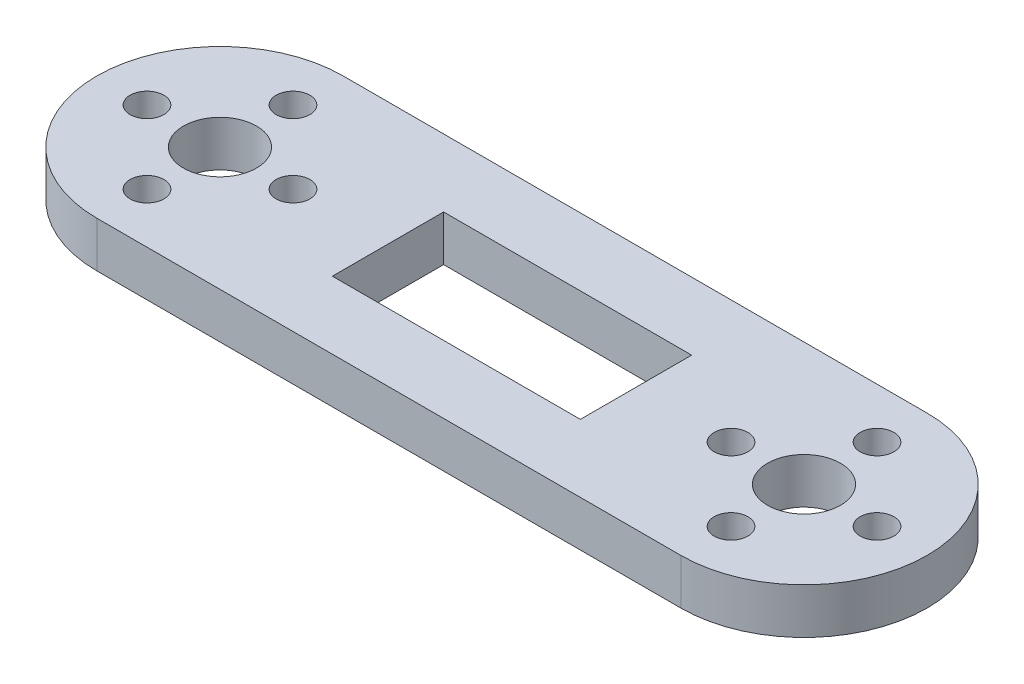
from build123d import *

# Parameters (mm, degrees)
SKETCH1_R           = 1.85
SKETCH1_R_2         = 4
SKETCH1_W           = 27.178
SKETCH1_H           = 12.192
BOSS_EXTRUDE1_DEPTH = 5


with BuildPart() as part:
    # Sketch1 → Boss-Extrude1 (new body)
    with BuildSketch(Plane(origin=(0, 5, 0), x_dir=(1, 0, 0), z_dir=(0, 1, 0))):
        with BuildLine():
            Line((64, 13.5), (0, 13.5))
            ThreePointArc((0, 13.5), (-13.5, 0), (0, -13.5))
            Line((0, -13.5), (64, -13.5))
            ThreePointArc((64, -13.5), (77.5, 0), (64, 13.5))
        make_face()
        with Locations((56, 0)):
            Circle(SKETCH1_R, mode=Mode.SUBTRACT)
        with Locations((64, -8)):
            Circle(SKETCH1_R, mode=Mode.SUBTRACT)
        with Locations((72, 0)):
            Circle(SKETCH1_R, mode=Mode.SUBTRACT)
        with Locations((64, 8)):
            Circle(SKETCH1_R, mode=Mode.SUBTRACT)
        with Locations((64, 0)):
            Circle(SKETCH1_R_2, mode=Mode.SUBTRACT)
        with Locations((-8, 0)):
            Circle(SKETCH1_R, mode=Mode.SUBTRACT)
        with Locations((0, -8)):
            Circle(SKETCH1_R, mode=Mode.SUBTRACT)
        with Locations((8, 0)):
            Circle(SKETCH1_R, mode=Mode.SUBTRACT)
        with Locations((0, 8)):
            Circle(SKETCH1_R, mode=Mode.SUBTRACT)
        Circle(SKETCH1_R_2, mode=Mode.SUBTRACT)
        with Locations((32, 0)):
            Rectangle(SKETCH1_W, SKETCH1_H, mode=Mode.SUBTRACT)
    extrude(amount=-BOSS_EXTRUDE1_DEPTH)


solid = part.part
